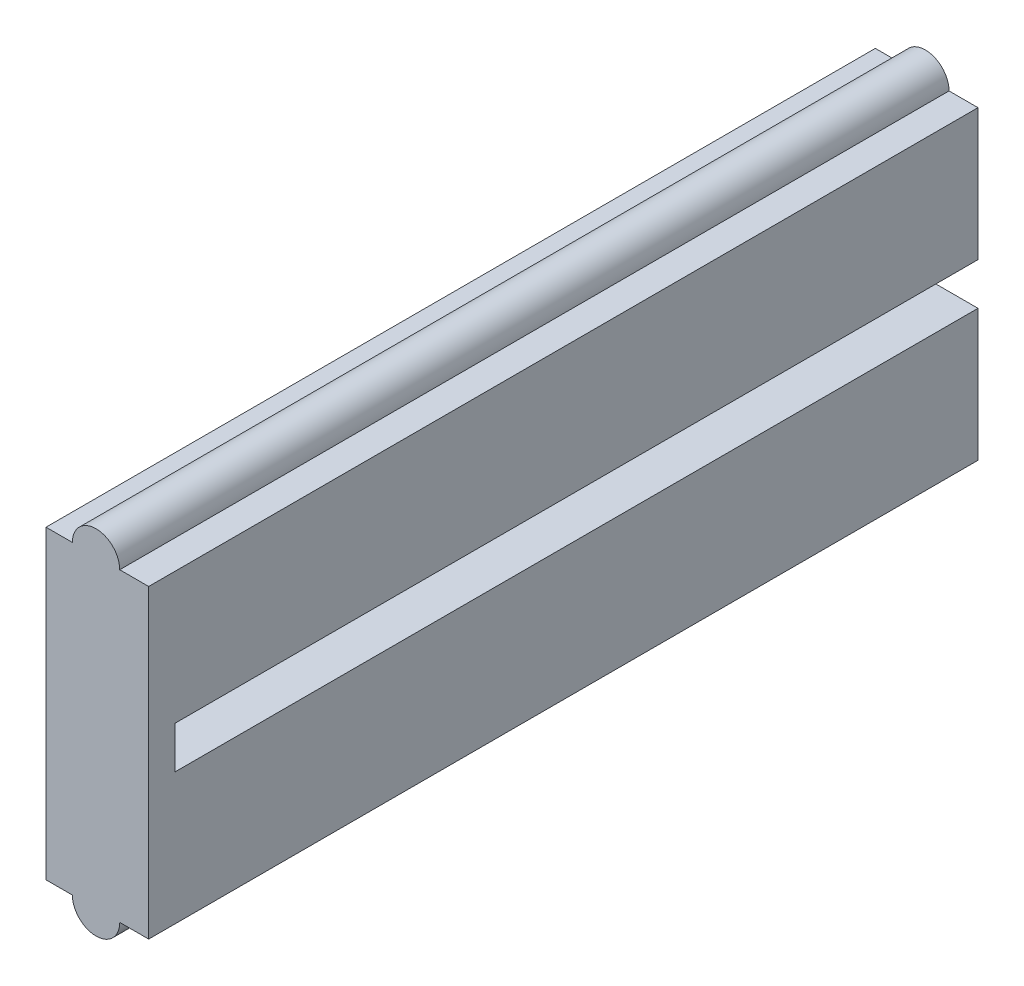
from build123d import *

# Parameters (mm, degrees)
BOSS_EXTRUDE1_DEPTH = 31.5
BOSS_EXTRUDE2_START = -31.5
SKETCH2_W           = 2
SKETCH2_H           = 1.6
BOSS_EXTRUDE2_DEPTH = 1


with BuildPart() as part:
    # Sketch1 → Boss-Extrude1 (new body)
    with BuildSketch(Plane.XY):
        with BuildLine():
            Line((-1.9, 5.8), (-0.9, 5.8))
            ThreePointArc((-0.9, 5.8), (0, 6.7), (0.9, 5.8))
            Line((0.9, 5.8), (2, 5.8))
            Line((2, 5.8), (2, 0.8))
            Line((2, 0.8), (0, 0.8))
            Line((0, 0.8), (0, -0.8))
            Line((0, -0.8), (2, -0.8))
            Line((2, -0.8), (2, -5.8))
            Line((2, -5.8), (0.90202041, -5.8))
            ThreePointArc((0.90202041, -5.8), (0.00202041, -6.7), (-0.89797959, -5.8))
            Line((-0.89797959, -5.8), (-1.9, -5.8))
            Line((-1.9, -5.8), (-1.9, 5.8))
        make_face()
    extrude(amount=BOSS_EXTRUDE1_DEPTH)

    # Sketch2 → Boss-Extrude2 (add)
    with BuildSketch(Plane(origin=(0, 0, 0), x_dir=(-1, 0, 0), z_dir=(0, 0, -1)).offset(BOSS_EXTRUDE2_START)):
        with Locations((-1, 0)):
            Rectangle(SKETCH2_W, SKETCH2_H)
    extrude(amount=BOSS_EXTRUDE2_DEPTH)


solid = part.part
